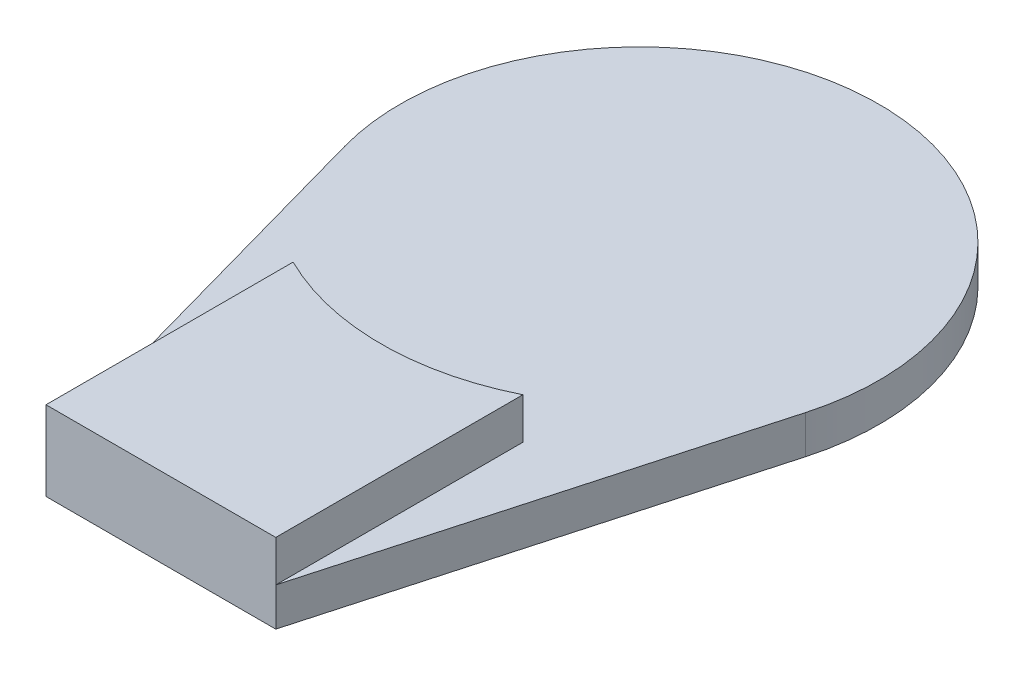
from build123d import *

# Parameters (mm, degrees)
BOSS_EXTRUDE1_DEPTH = 2
BOSS_EXTRUDE2_DEPTH = 2.15


with BuildPart() as part:
    # Sketch1 → Boss-Extrude1 (new body)
    with BuildSketch(Plane(origin=(0, 0, 0), x_dir=(1, 0, 0), z_dir=(0, 1, 0))):
        with BuildLine():
            Line((-12.039826938, -3.360441535), (-6, -25))
            Line((-6, -25), (6, -25))
            Line((6, -25), (12.039826938, -3.360441535))
            ThreePointArc((12.039826938, -3.360441535), (0, 12.5), (-12.039826938, -3.360441535))
        make_face()
    extrude(amount=BOSS_EXTRUDE1_DEPTH)

    # Sketch2 → Boss-Extrude2 (add)
    with BuildSketch(Plane(origin=(0, 2, 0), x_dir=(1, 0, 0), z_dir=(0, 1, 0))):
        with BuildLine():
            Line((-6, -25), (-6, -12.093386622))
            ThreePointArc((-6, -12.093386622), (0, -13.5), (6, -12.093386622))
            Line((6, -12.093386622), (6, -25))
            Line((6, -25), (-6, -25))
        make_face()
    extrude(amount=BOSS_EXTRUDE2_DEPTH)


solid = part.part
